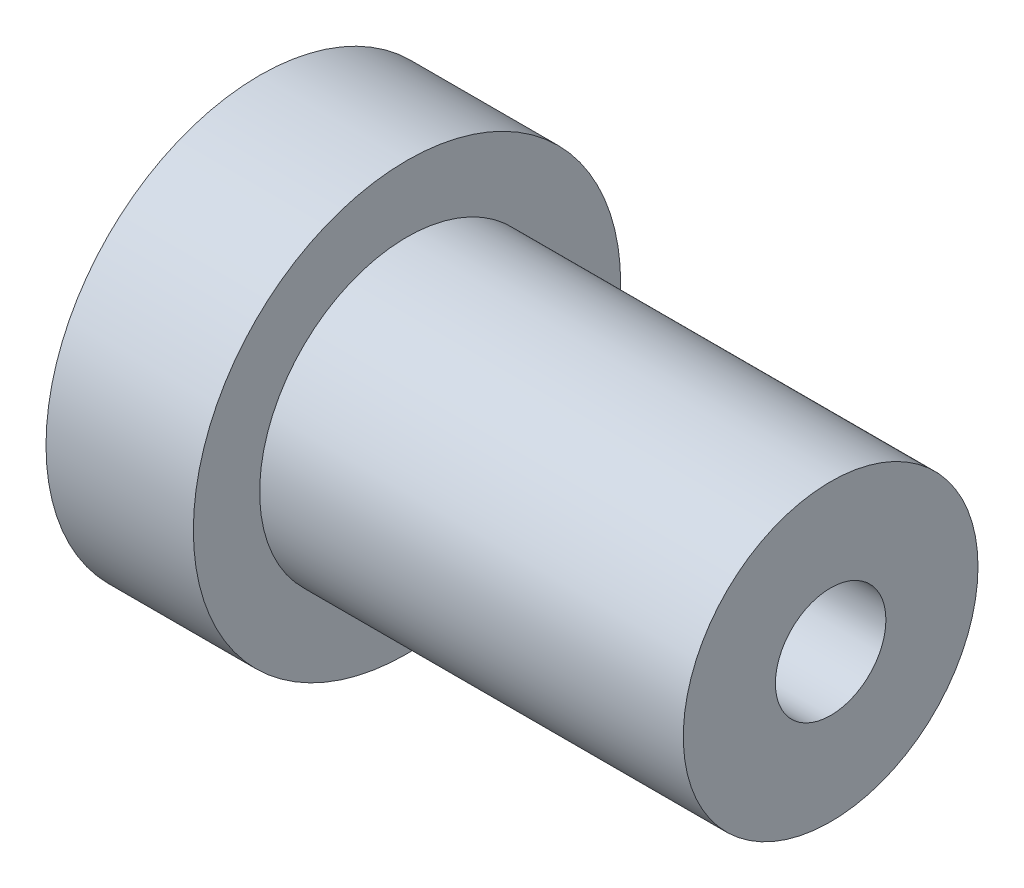
from build123d import *

# Parameters (mm, degrees)
SKETCH1_R           = 5.8
BOSS_EXTRUDE1_DEPTH = 4
SKETCH2_R           = 4
BOSS_EXTRUDE2_DEPTH = 11.5
SKETCH3_R           = 1.5
CUT_EXTRUDE1_DEPTH  = 20
SKETCH4_R           = 3
CUT_EXTRUDE2_DEPTH  = 3


with BuildPart() as part:
    # Sketch1 → Boss-Extrude1 (new body)
    with BuildSketch(Plane(origin=(0, 0, 0), x_dir=(0, 0, -1), z_dir=(1, 0, 0))):
        Circle(SKETCH1_R)
    extrude(amount=BOSS_EXTRUDE1_DEPTH)

    # Sketch2 → Boss-Extrude2 (add)
    with BuildSketch(Plane(origin=(4, 0, 0), x_dir=(0, 0, -1), z_dir=(1, 0, 0))):
        Circle(SKETCH2_R)
    extrude(amount=BOSS_EXTRUDE2_DEPTH)

    # Sketch3 → Cut-Extrude1 (cut)
    with BuildSketch(Plane.ZY):
        Circle(SKETCH3_R)
    extrude(amount=-CUT_EXTRUDE1_DEPTH, mode=Mode.SUBTRACT)

    # Sketch4 → Cut-Extrude2 (cut)
    with BuildSketch(Plane.ZY):
        Circle(SKETCH4_R)
    extrude(amount=-CUT_EXTRUDE2_DEPTH, mode=Mode.SUBTRACT)


solid = part.part
